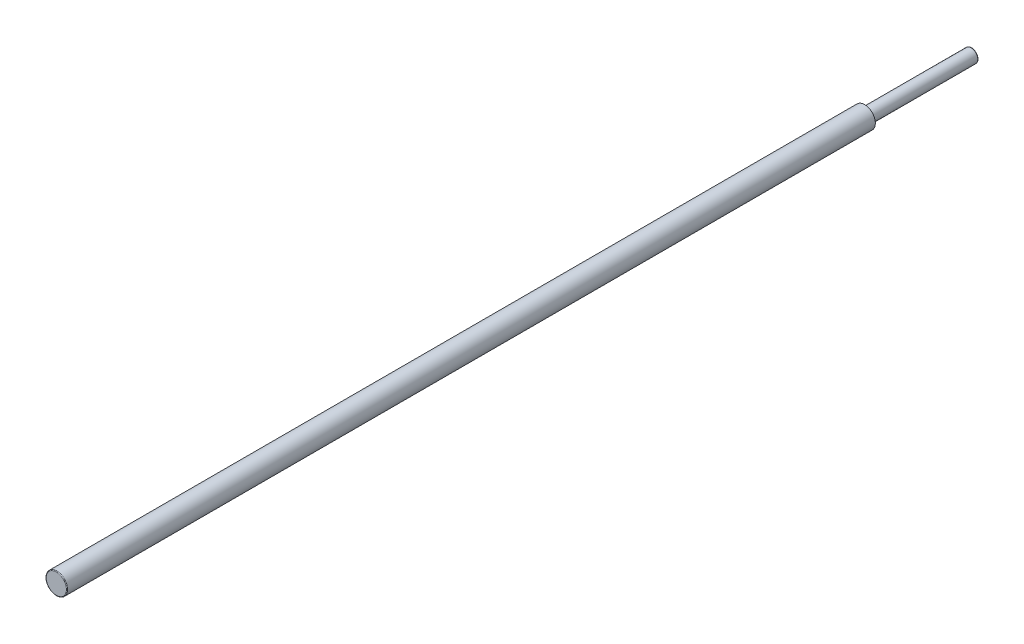
from build123d import *

# Parameters (mm, degrees)
SKETCH1_R           = 2.5
EXTRUDE1_DEPTH      = 40
SKETCH2_R           = 4
BOSS_EXTRUDE1_DEPTH = 302
FILLET1_R           = 0.25


with BuildPart() as part:
    # Sketch1 → Extrude1 (new body)
    with BuildSketch(Plane.XY):
        Circle(SKETCH1_R)
    extrude(amount=EXTRUDE1_DEPTH)

    # Sketch2 → Boss-Extrude1 (add)
    with BuildSketch(Plane.XY.offset(40)):
        Circle(SKETCH2_R)
    extrude(amount=BOSS_EXTRUDE1_DEPTH)

    # Fillet1
    fillet1_edges = [part.edges().sort_by_distance(p)[0] for p in [
        (-2.5, 0, 0),
        (-4, 0, 342),
    ]]
    fillet(fillet1_edges, radius=FILLET1_R)


solid = part.part
